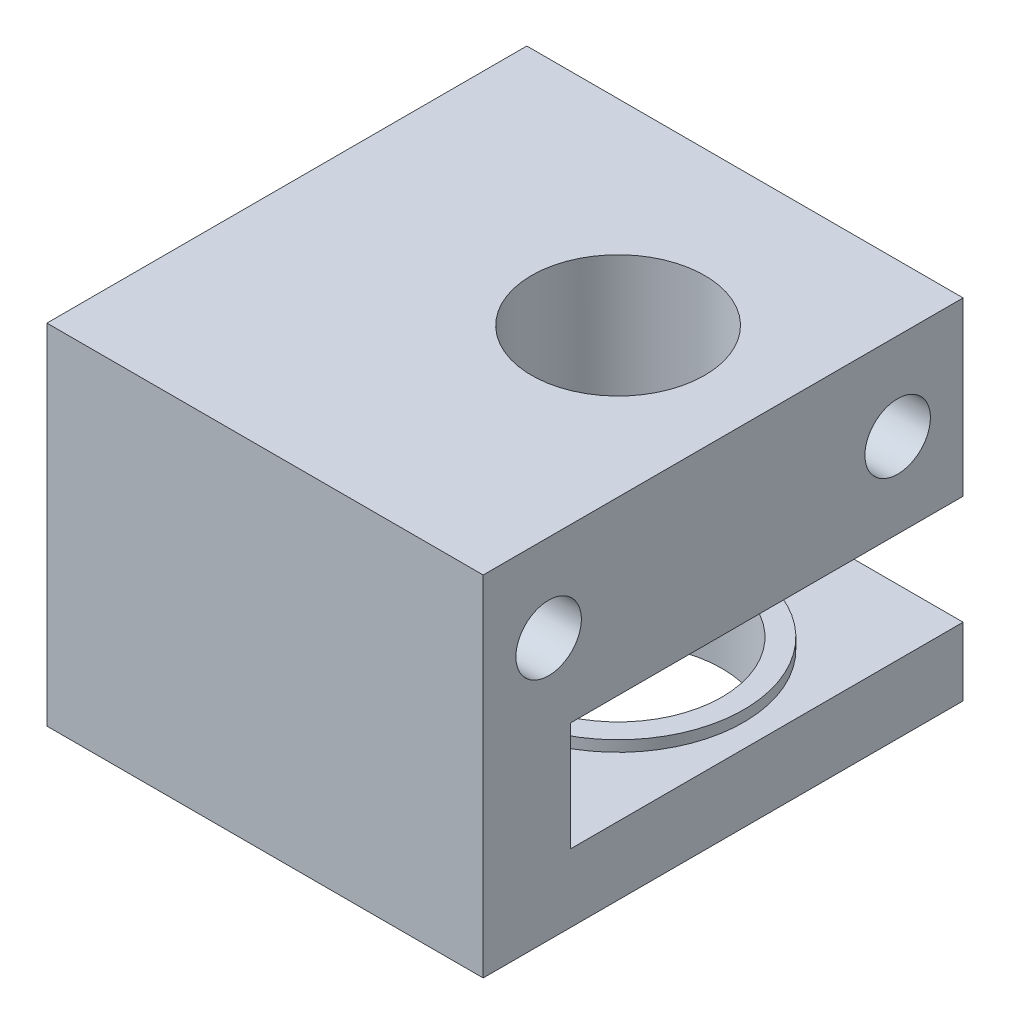
from build123d import *

# Parameters (mm, degrees)
SKETCH1_W               = 20
SKETCH1_H               = 22
BOSS_EXTRUDE1_DEPTH     = 16
SKETCH2_W               = 15
SKETCH2_H               = 5
CUT_EXTRUDE1_DEPTH      = 23
SKETCH3_R               = 3.96875
CUT_EXTRUDE2_DEPTH      = 13.875
CUT_EXTRUDE2_DEPTH_BACK = 4.125
CUT_EXTRUDE3_REACH      = 18
SKETCH4_R               = 4.7625
SKETCH5_R               = 5.762499999
SKETCH5_R_2             = 4.762499999
BOSS_EXTRUDE2_DEPTH     = 0.5
SKETCH6_R               = 5.2625
SKETCH6_R_2             = 3.96875
BOSS_EXTRUDE3_DEPTH     = 0.5
BOSS_EXTRUDE4_REACH     = 14.875
SKETCH7_W               = 15
SKETCH7_H               = 4
SKETCH9_R               = 1.5
CUT_EXTRUDE4_DEPTH      = 21


with BuildPart() as part:
    # Sketch1 → Boss-Extrude1 (new body)
    with BuildSketch(Plane(origin=(0, 0, 0), x_dir=(1, 0, 0), z_dir=(0, 1, 0))):
        with Locations((10, 11)):
            Rectangle(SKETCH1_W, SKETCH1_H)
    extrude(amount=BOSS_EXTRUDE1_DEPTH)

    # Sketch2 → Cut-Extrude1 (cut, through all)
    with BuildSketch(Plane(origin=(0, 0, -22), x_dir=(-1, 0, 0), z_dir=(0, 0, -1))):
        with Locations((-12.5, 5.625)):
            Rectangle(SKETCH2_W, SKETCH2_H)
    extrude(amount=-CUT_EXTRUDE1_DEPTH, mode=Mode.SUBTRACT)

    # Sketch3 → Cut-Extrude2 (cut, two sides)
    with BuildSketch(Plane(origin=(0, 3.125, 0), x_dir=(1, 0, 0), z_dir=(0, 1, 0))) as cut_extrude2_sk:
        with Locations((13.184494174, 13)):
            Circle(SKETCH3_R)
    extrude(amount=CUT_EXTRUDE2_DEPTH, mode=Mode.SUBTRACT)
    extrude(cut_extrude2_sk.sketch, amount=-CUT_EXTRUDE2_DEPTH_BACK, mode=Mode.SUBTRACT)

    # Sketch4 → Cut-Extrude3 (cut, up to next)
    with BuildSketch(Plane.XZ, mode=Mode.PRIVATE) as cut_extrude3_sk1:
        with Locations((13.184494174, -13)):
            Circle(SKETCH4_R)
    cut_extrude3_tool1 = extrude(cut_extrude3_sk1.sketch, amount=-CUT_EXTRUDE3_REACH, mode=Mode.PRIVATE) & part.part
    add(cut_extrude3_tool1.solids().sort_by_distance((13.184494, 0, -13))[0], mode=Mode.SUBTRACT)

    # Sketch5 → Boss-Extrude2 (add)
    with BuildSketch(Plane(origin=(0, 3.125, 0), x_dir=(1, 0, 0), z_dir=(0, 1, 0))):
        with Locations((13.184494174, 13)):
            Circle(SKETCH5_R)
        with Locations((13.184494174, 13)):
            Circle(SKETCH5_R_2, mode=Mode.SUBTRACT)
    extrude(amount=BOSS_EXTRUDE2_DEPTH)

    # Sketch6 → Boss-Extrude3 (add)
    with BuildSketch(Plane.XZ.offset(-8.125)):
        with Locations((13.184494174, -13)):
            Circle(SKETCH6_R)
        with Locations((13.184494174, -13)):
            Circle(SKETCH6_R_2, mode=Mode.SUBTRACT)
    extrude(amount=BOSS_EXTRUDE3_DEPTH)

    # Sketch7 → Boss-Extrude4 (add, up to next)
    with BuildSketch(Plane(origin=(0, 3.125, 0), x_dir=(1, 0, 0), z_dir=(0, 1, 0)), mode=Mode.PRIVATE) as boss_extrude4_sk1:
        with Locations((12.5, 2)):
            Rectangle(SKETCH7_W, SKETCH7_H)
    boss_extrude4_tool1 = extrude(boss_extrude4_sk1.sketch, amount=BOSS_EXTRUDE4_REACH, mode=Mode.PRIVATE) - part.part
    add(boss_extrude4_tool1.solids().sort_by_distance((12.5, 3.125, -2))[0])

    # Sketch9 → Cut-Extrude4 (cut, through all)
    with BuildSketch(Plane.ZY):
        with Locations((-3, 12)):
            Circle(SKETCH9_R)
        with Locations((-19, 12)):
            Circle(SKETCH9_R)
    extrude(amount=-CUT_EXTRUDE4_DEPTH, mode=Mode.SUBTRACT)


solid = part.part
